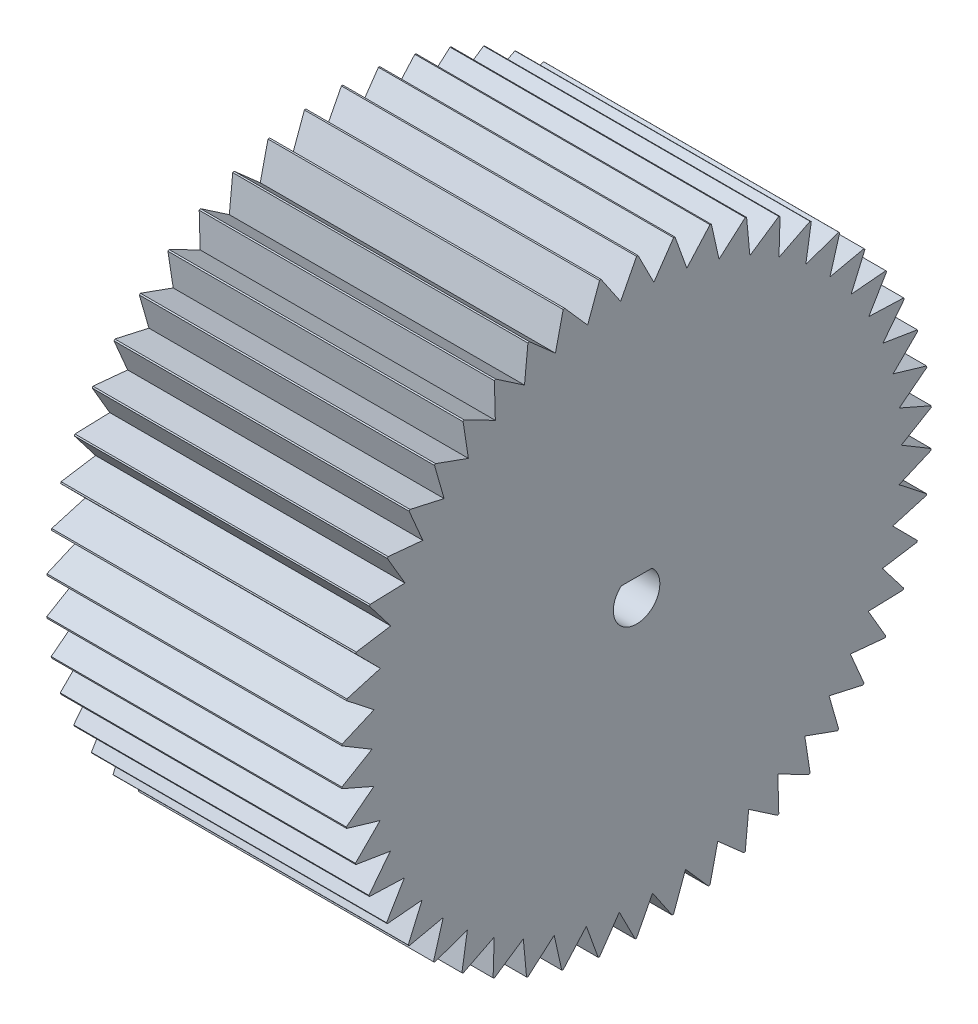
from build123d import *

# Parameters (mm, degrees)
BOSS_EXTRUDE1_DEPTH = 25.4


with BuildPart() as part:
    # Sketch1 → Boss-Extrude1 (new body)
    with BuildSketch(Plane(origin=(0, 0, 0), x_dir=(0, 0, -1), z_dir=(1, 0, 0))):
        with BuildLine():
            Line((-3.058165342, 25.21522605), (-1.373518571, 22.73289544))
            Line((-1.373518571, 22.73289544), (0, 25.4))
            ThreePointArc((0, 25.4), (0.063127705, 25.399921553), (0.126255021, 25.399686212))
            Line((0.126255021, 25.399686212), (1.486499327, 22.725787293))
            Line((1.486499327, 22.725787293), (3.183464133, 25.199713413))
            ThreePointArc((3.183464133, 25.199713413), (3.246084225, 25.191723585), (3.308684267, 25.18357815))
            Line((3.308684267, 25.18357815), (4.323074242, 22.360279905))
            Line((4.323074242, 22.360279905), (6.316723134, 24.602012293))
            ThreePointArc((6.316723134, 24.602012293), (6.377848057, 24.586237088), (6.438933585, 24.570310016))
            Line((6.438933585, 24.570310016), (7.091471695, 21.642137546))
            Line((7.091471695, 21.642137546), (9.350363638, 23.616322742))
            ThreePointArc((9.350363638, 23.616322742), (9.409029416, 23.593010945), (9.467637075, 23.569553416))
            Line((9.467637075, 23.569553416), (9.748032402, 20.582685749))
            Line((9.748032402, 20.582685749), (12.236543322, 22.258189673))
            ThreePointArc((12.236543322, 22.258189673), (12.29182476, 22.227708925), (12.347030272, 22.197090879))
            Line((12.347030272, 22.197090879), (12.250860815, 19.198632702))
            Line((12.250860815, 19.198632702), (14.929745408, 20.549031657))
            ThreePointArc((14.929745408, 20.549031657), (14.980770685, 20.511862658), (15.031703426, 20.474566958))
            Line((15.031703426, 20.474566958), (14.560485835, 17.511805749))
            Line((14.560485835, 17.511805749), (17.387496491, 18.515803137))
            ThreePointArc((17.387496491, 18.515803137), (17.433460907, 18.472532063), (17.479317637, 18.429146886))
            Line((17.479317637, 18.429146886), (16.640483295, 15.548807158))
            Line((16.640483295, 15.548807158), (19.571036367, 16.19056934))
            ThreePointArc((19.571036367, 16.19056934), (19.611215036, 16.141878603), (19.651272568, 16.093088158))
            Line((19.651272568, 16.093088158), (18.458050394, 13.34059459))
            Line((18.458050394, 13.34059459), (21.445929308, 13.610000592))
            ThreePointArc((21.445929308, 13.610000592), (21.479688589, 13.556658074), (21.513315191, 13.503231817))
            Line((21.513315191, 13.503231817), (19.984523011, 10.921992876))
            Line((19.984523011, 10.921992876), (22.982607133, 10.814794006))
            ThreePointArc((22.982607133, 10.814794006), (23.009414621, 10.757640949), (23.036079982, 10.700421443))
            Line((23.036079982, 10.700421443), (21.195827762, 8.33114481))
            Line((21.195827762, 8.33114481), (24.156835514, 7.849031657))
            ThreePointArc((24.156835514, 7.849031657), (24.17626844, 7.7889694), (24.195552031, 7.728859031))
            Line((24.195552031, 7.728859031), (22.072861647, 5.608909613))
            Line((22.072861647, 5.608909613), (24.950096169, 4.75948539))
            ThreePointArc((24.950096169, 4.75948539), (24.961848063, 4.697461151), (24.97344577, 4.635407895))
            Line((24.97344577, 4.635407895), (22.601793319, 2.798218561))
            Line((22.601793319, 2.798218561), (25.349878902, 1.594879196))
            ThreePointArc((25.349878902, 1.594879196), (25.353764431, 1.531871133), (25.357493352, 1.468853608))
            Line((25.357493352, 1.468853608), (22.774281208, -0.056602069))
            Line((22.774281208, -0.056602069), (25.349878902, -1.594879196))
            ThreePointArc((25.349878902, -1.594879196), (25.345836788, -1.657877407), (25.341638115, -1.720865378))
            Line((25.341638115, -1.720865378), (22.587605078, -2.910530051))
            Line((22.587605078, -2.910530051), (24.950096169, -4.75948539))
            ThreePointArc((24.950096169, -4.75948539), (24.938190159, -4.821480231), (24.926130107, -4.88344529))
            Line((24.926130107, -4.88344529), (22.044708923, -5.718557235))
            Line((22.044708923, -5.718557235), (24.156835514, -7.849031657))
            ThreePointArc((24.156835514, -7.849031657), (24.137253373, -7.909045431), (24.117522137, -7.969010351))
            Line((24.117522137, -7.969010351), (21.154154539, -8.436399355))
            Line((21.154154539, -8.436399355), (22.982607133, -10.814794006))
            ThreePointArc((22.982607133, -10.814794006), (22.955657682, -10.87188026), (22.928566436, -10.928899359))
            Line((22.928566436, -10.928899359), (19.929986501, -11.021194418))
            Line((19.929986501, -11.021194418), (21.445929308, -13.610000592))
            ThreePointArc((21.445929308, -13.610000592), (21.412037557, -13.663259043), (21.378013545, -13.716433096))
            Line((21.378013545, -13.716433096), (18.391510671, -13.432178662))
            Line((18.391510671, -13.432178662), (19.571036367, -16.19056934))
            ThreePointArc((19.571036367, -16.19056934), (19.530736808, -16.239160068), (19.49031661, -16.287650489))
            Line((19.49031661, -16.287650489), (16.56298973, -15.631329423))
            Line((16.56298973, -15.631329423), (17.387496491, -18.515803137))
            ThreePointArc((17.387496491, -18.515803137), (17.341424673, -18.558959839), (17.295245739, -18.602001904))
            Line((17.295245739, -18.602001904), (14.473260548, -17.583964782))
            Line((14.473260548, -17.583964782), (14.929745408, -20.549031657))
            ThreePointArc((14.929745408, -20.549031657), (14.878627912, -20.586073726), (14.827418511, -20.622988636))
            Line((14.827418511, -20.622988636), (12.1552794, -19.259290513))
            Line((12.1552794, -19.259290513), (12.236543322, -22.258189673))
            ThreePointArc((12.236543322, -22.258189673), (12.1811863, -22.288532933), (12.125754036, -22.318738519))
            Line((12.125754036, -22.318738519), (9.645602236, -20.630885727))
            Line((9.645602236, -20.630885727), (9.350363638, -23.616322742))
            ThreePointArc((9.350363638, -23.616322742), (9.291640104, -23.639488662), (9.232859176, -23.662508562))
            Line((9.232859176, -23.662508562), (6.983808161, -21.677119548))
            Line((6.983808161, -21.677119548), (6.316723134, -24.602012293))
            ThreePointArc((6.316723134, -24.602012293), (6.255559193, -24.617635532), (6.194356611, -24.63310671))
            Line((6.194356611, -24.63310671), (4.211875261, -22.381492245))
            Line((4.211875261, -22.381492245), (3.183464133, -25.199713413))
            ThreePointArc((3.183464133, -25.199713413), (3.120824376, -25.207547584), (3.058165342, -25.21522605))
            Line((3.058165342, -25.21522605), (1.373518571, -22.73289544))
            Line((1.373518571, -22.73289544), (0, -25.4))
            ThreePointArc((0, -25.4), (-0.063127705, -25.399921553), (-0.126255021, -25.399686212))
            Line((-0.126255021, -25.399686212), (-1.486499327, -22.725787293))
            Line((-1.486499327, -22.725787293), (-3.183464133, -25.199713413))
            ThreePointArc((-3.183464133, -25.199713413), (-3.246084225, -25.191723585), (-3.308684267, -25.18357815))
            Line((-3.308684267, -25.18357815), (-4.323074242, -22.360279905))
            Line((-4.323074242, -22.360279905), (-6.316723134, -24.602012293))
            ThreePointArc((-6.316723134, -24.602012293), (-6.377848057, -24.586237088), (-6.438933585, -24.570310016))
            Line((-6.438933585, -24.570310016), (-7.091471695, -21.642137546))
            Line((-7.091471695, -21.642137546), (-9.350363638, -23.616322742))
            ThreePointArc((-9.350363638, -23.616322742), (-9.409029416, -23.593010945), (-9.467637075, -23.569553416))
            Line((-9.467637075, -23.569553416), (-9.748032402, -20.582685749))
            Line((-9.748032402, -20.582685749), (-12.236543322, -22.258189673))
            ThreePointArc((-12.236543322, -22.258189673), (-12.29182476, -22.227708925), (-12.347030272, -22.197090879))
            Line((-12.347030272, -22.197090879), (-12.250860815, -19.198632702))
            Line((-12.250860815, -19.198632702), (-14.929745408, -20.549031657))
            ThreePointArc((-14.929745408, -20.549031657), (-14.980770685, -20.511862658), (-15.031703426, -20.474566958))
            Line((-15.031703426, -20.474566958), (-14.560485835, -17.511805749))
            Line((-14.560485835, -17.511805749), (-17.387496491, -18.515803137))
            ThreePointArc((-17.387496491, -18.515803137), (-17.433460907, -18.472532063), (-17.479317637, -18.429146886))
            Line((-17.479317637, -18.429146886), (-16.640483295, -15.548807158))
            Line((-16.640483295, -15.548807158), (-19.571036367, -16.19056934))
            ThreePointArc((-19.571036367, -16.19056934), (-19.611215036, -16.141878603), (-19.651272568, -16.093088158))
            Line((-19.651272568, -16.093088158), (-18.458050394, -13.34059459))
            Line((-18.458050394, -13.34059459), (-21.445929308, -13.610000592))
            ThreePointArc((-21.445929308, -13.610000592), (-21.479688589, -13.556658074), (-21.513315191, -13.503231817))
            Line((-21.513315191, -13.503231817), (-19.984523011, -10.921992876))
            Line((-19.984523011, -10.921992876), (-22.982607133, -10.814794006))
            ThreePointArc((-22.982607133, -10.814794006), (-23.009414621, -10.757640949), (-23.036079982, -10.700421443))
            Line((-23.036079982, -10.700421443), (-21.195827762, -8.33114481))
            Line((-21.195827762, -8.33114481), (-24.156835514, -7.849031657))
            ThreePointArc((-24.156835514, -7.849031657), (-24.17626844, -7.7889694), (-24.195552031, -7.728859031))
            Line((-24.195552031, -7.728859031), (-22.072861647, -5.608909613))
            Line((-22.072861647, -5.608909613), (-24.950096169, -4.75948539))
            ThreePointArc((-24.950096169, -4.75948539), (-24.961848063, -4.697461151), (-24.97344577, -4.635407895))
            Line((-24.97344577, -4.635407895), (-22.601793319, -2.798218561))
            Line((-22.601793319, -2.798218561), (-25.349878902, -1.594879196))
            ThreePointArc((-25.349878902, -1.594879196), (-25.353764431, -1.531871133), (-25.357493352, -1.468853608))
            Line((-25.357493352, -1.468853608), (-22.774281208, 0.056602069))
            Line((-22.774281208, 0.056602069), (-25.349878902, 1.594879196))
            ThreePointArc((-25.349878902, 1.594879196), (-25.345836788, 1.657877407), (-25.341638115, 1.720865378))
            Line((-25.341638115, 1.720865378), (-22.587605078, 2.910530051))
            Line((-22.587605078, 2.910530051), (-24.950096169, 4.75948539))
            ThreePointArc((-24.950096169, 4.75948539), (-24.938190159, 4.821480231), (-24.926130107, 4.88344529))
            Line((-24.926130107, 4.88344529), (-22.044708923, 5.718557235))
            Line((-22.044708923, 5.718557235), (-24.156835514, 7.849031657))
            ThreePointArc((-24.156835514, 7.849031657), (-24.137253373, 7.909045431), (-24.117522137, 7.969010351))
            Line((-24.117522137, 7.969010351), (-21.154154539, 8.436399355))
            Line((-21.154154539, 8.436399355), (-22.982607133, 10.814794006))
            ThreePointArc((-22.982607133, 10.814794006), (-22.955657682, 10.87188026), (-22.928566436, 10.928899359))
            Line((-22.928566436, 10.928899359), (-19.929986501, 11.021194418))
            Line((-19.929986501, 11.021194418), (-21.445929308, 13.610000592))
            ThreePointArc((-21.445929308, 13.610000592), (-21.412037557, 13.663259043), (-21.378013545, 13.716433096))
            Line((-21.378013545, 13.716433096), (-18.391510671, 13.432178662))
            Line((-18.391510671, 13.432178662), (-19.571036367, 16.19056934))
            ThreePointArc((-19.571036367, 16.19056934), (-19.530736808, 16.239160068), (-19.49031661, 16.287650489))
            Line((-19.49031661, 16.287650489), (-16.56298973, 15.631329423))
            Line((-16.56298973, 15.631329423), (-17.387496491, 18.515803137))
            ThreePointArc((-17.387496491, 18.515803137), (-17.341424673, 18.558959839), (-17.295245739, 18.602001904))
            Line((-17.295245739, 18.602001904), (-14.473260548, 17.583964782))
            Line((-14.473260548, 17.583964782), (-14.929745408, 20.549031657))
            ThreePointArc((-14.929745408, 20.549031657), (-14.878627912, 20.586073726), (-14.827418511, 20.622988636))
            Line((-14.827418511, 20.622988636), (-12.1552794, 19.259290513))
            Line((-12.1552794, 19.259290513), (-12.236543322, 22.258189673))
            ThreePointArc((-12.236543322, 22.258189673), (-12.1811863, 22.288532933), (-12.125754036, 22.318738519))
            Line((-12.125754036, 22.318738519), (-9.645602236, 20.630885727))
            Line((-9.645602236, 20.630885727), (-9.350363638, 23.616322742))
            ThreePointArc((-9.350363638, 23.616322742), (-9.291640104, 23.639488662), (-9.232859176, 23.662508562))
            Line((-9.232859176, 23.662508562), (-6.983808161, 21.677119548))
            Line((-6.983808161, 21.677119548), (-6.316723134, 24.602012293))
            ThreePointArc((-6.316723134, 24.602012293), (-6.255559193, 24.617635532), (-6.194356611, 24.63310671))
            Line((-6.194356611, 24.63310671), (-4.211875261, 22.381492245))
            Line((-4.211875261, 22.381492245), (-3.183464133, 25.199713413))
            ThreePointArc((-3.183464133, 25.199713413), (-3.120824376, 25.207547584), (-3.058165342, 25.21522605))
        make_face()
        with BuildLine():
            Line((-1.322875656, 1.5), (1.322875656, 1.5))
            ThreePointArc((1.322875656, 1.5), (0, -2), (-1.322875656, 1.5))
        make_face(mode=Mode.SUBTRACT)
    extrude(amount=BOSS_EXTRUDE1_DEPTH)


solid = part.part
